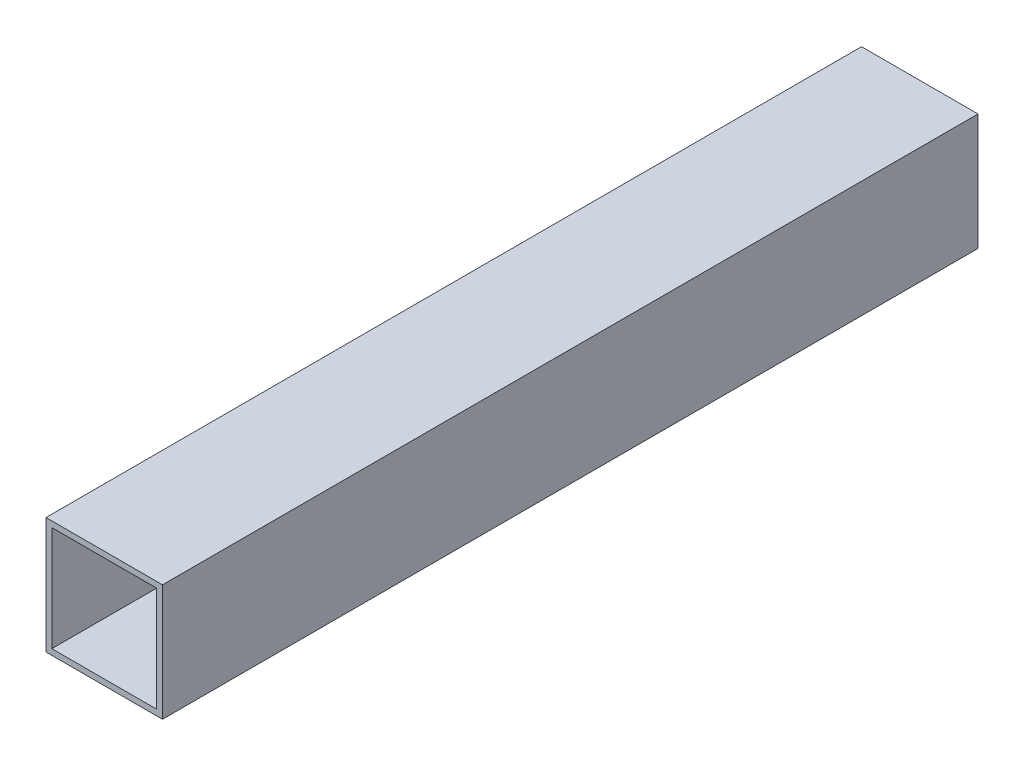
from build123d import *

# Parameters (mm, degrees)
SKETCH1_W           = 25.4
SKETCH1_H           = 25.4
BOSS_EXTRUDE1_DEPTH = 177.8
SKETCH2_W           = 22.86
SKETCH2_H           = 22.86
CUT_EXTRUDE1_DEPTH  = 177.8


with BuildPart() as part:
    # Sketch1 → Boss-Extrude1 (new body)
    with BuildSketch(Plane.XY):
        with Locations((12.7, 12.7)):
            Rectangle(SKETCH1_W, SKETCH1_H)
    extrude(amount=BOSS_EXTRUDE1_DEPTH)

    # Sketch2 → Cut-Extrude1 (cut)
    with BuildSketch(Plane.XY.offset(177.8)):
        with Locations((12.7, 12.7)):
            Rectangle(SKETCH2_W, SKETCH2_H)
    extrude(amount=-CUT_EXTRUDE1_DEPTH, mode=Mode.SUBTRACT)


solid = part.part
